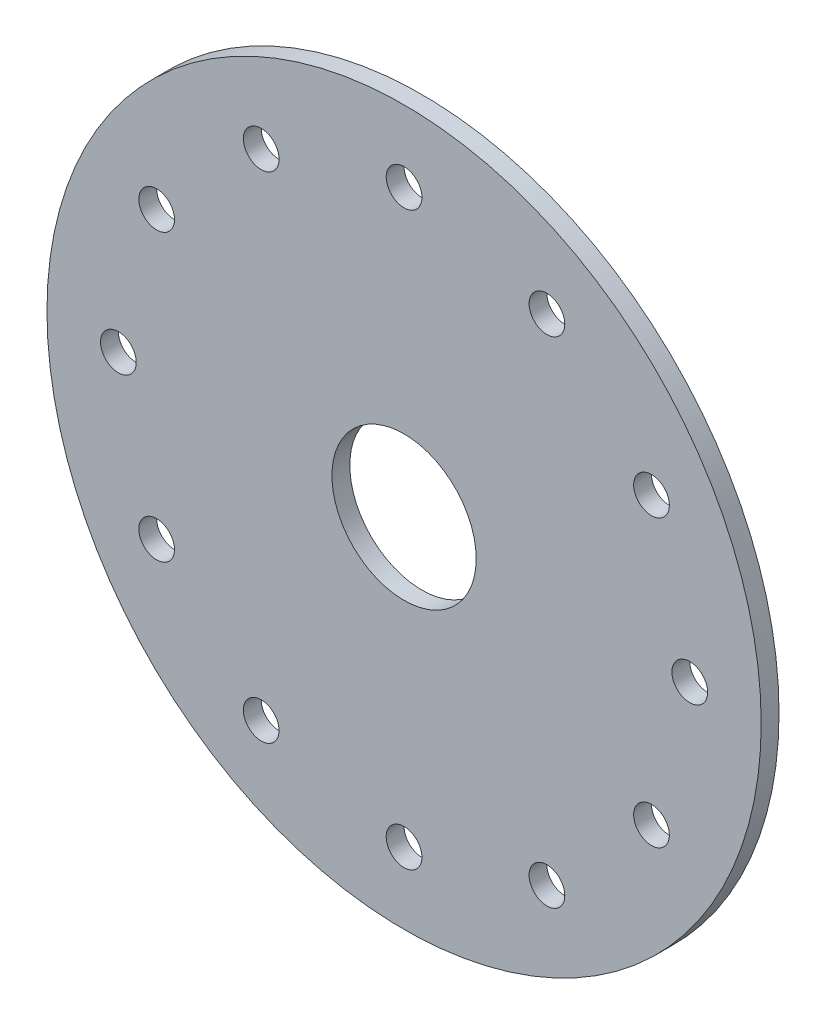
from build123d import *

# Parameters (mm, degrees)
SKETCH1_R           = 31.75
SKETCH1_R_2         = 1.5875
SKETCH1_R_3         = 6.4135
BOSS_EXTRUDE1_DEPTH = 1.5875


with BuildPart() as part:
    # Sketch1 → Boss-Extrude1 (new body)
    with BuildSketch(Plane.XY):
        with Locations((-90.81071762, 34.653984208)):
            Circle(SKETCH1_R)
        with Locations((-90.81071762, 60.053984208)):
            Circle(SKETCH1_R_2, mode=Mode.SUBTRACT)
        with Locations((-78.11071762, 56.651029464)):
            Circle(SKETCH1_R_2, mode=Mode.SUBTRACT)
        with Locations((-68.813672364, 47.353984208)):
            Circle(SKETCH1_R_2, mode=Mode.SUBTRACT)
        with Locations((-65.41071762, 34.653984208)):
            Circle(SKETCH1_R_2, mode=Mode.SUBTRACT)
        with Locations((-68.813672364, 21.953984208)):
            Circle(SKETCH1_R_2, mode=Mode.SUBTRACT)
        with Locations((-78.11071762, 12.656938952)):
            Circle(SKETCH1_R_2, mode=Mode.SUBTRACT)
        with Locations((-90.81071762, 9.253984208)):
            Circle(SKETCH1_R_2, mode=Mode.SUBTRACT)
        with Locations((-103.51071762, 12.656938952)):
            Circle(SKETCH1_R_2, mode=Mode.SUBTRACT)
        with Locations((-112.807762876, 21.953984208)):
            Circle(SKETCH1_R_2, mode=Mode.SUBTRACT)
        with Locations((-116.21071762, 34.653984208)):
            Circle(SKETCH1_R_2, mode=Mode.SUBTRACT)
        with Locations((-112.807762876, 47.353984208)):
            Circle(SKETCH1_R_2, mode=Mode.SUBTRACT)
        with Locations((-103.51071762, 56.651029464)):
            Circle(SKETCH1_R_2, mode=Mode.SUBTRACT)
        with Locations((-90.81071762, 34.653984208)):
            Circle(SKETCH1_R_3, mode=Mode.SUBTRACT)
    extrude(amount=BOSS_EXTRUDE1_DEPTH)


solid = part.part
